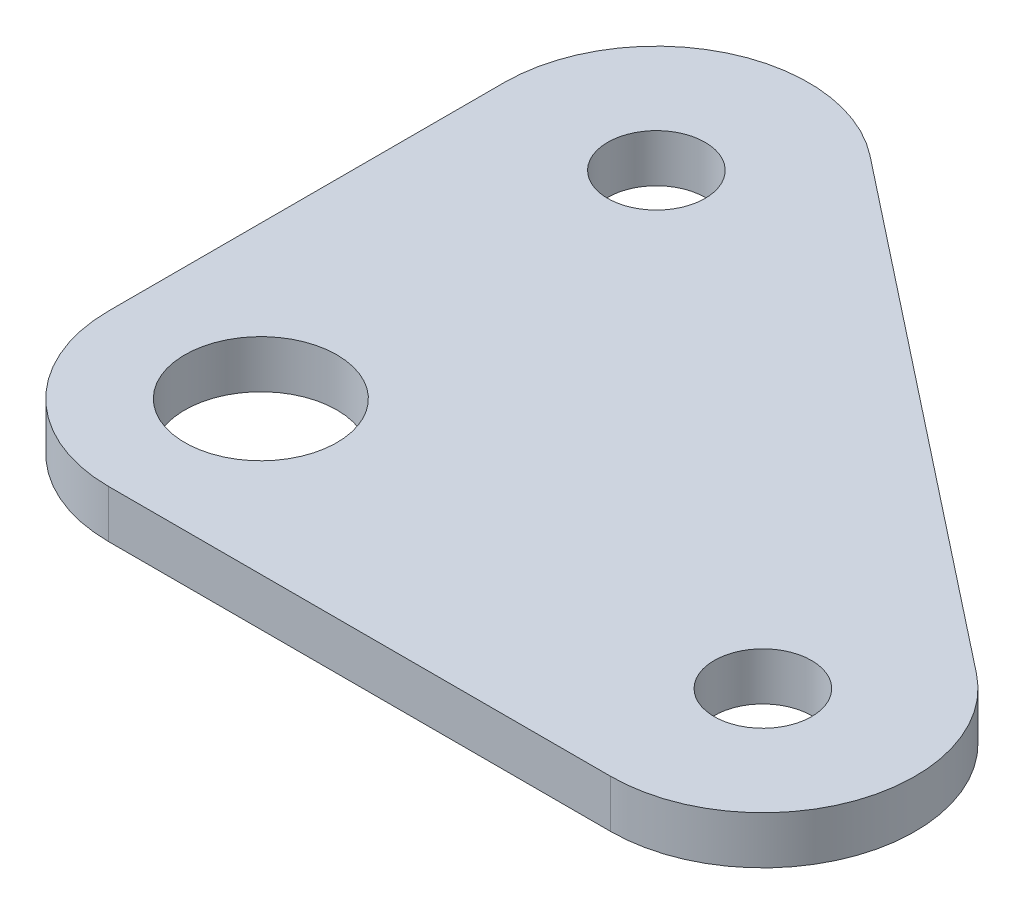
from build123d import *

# Parameters (mm, degrees)
SKETCH1_R           = 1.6
SKETCH1_R_2         = 2.5
BOSS_EXTRUDE1_DEPTH = 1.57


with BuildPart() as part:
    # Sketch1 → Boss-Extrude1 (new body)
    with BuildSketch(Plane(origin=(0, 1.57, 0), x_dir=(1, 0, 0), z_dir=(0, 1, 0))):
        with BuildLine():
            Line((0, -5), (16.5, -5))
            ThreePointArc((16.5, -5), (21.224261413, -1.637484075), (19.594361133, 3.927458361))
            Line((19.594361133, 3.927458361), (3.094361133, 16.927458361))
            ThreePointArc((3.094361133, 16.927458361), (-2.182681188, 17.498433375), (-5, 13))
            Line((-5, 13), (-5, 0))
            ThreePointArc((-5, 0), (-3.535533906, -3.535533906), (0, -5))
        make_face()
        with Locations((0, 13)):
            Circle(SKETCH1_R, mode=Mode.SUBTRACT)
        with Locations((16.5, 0)):
            Circle(SKETCH1_R, mode=Mode.SUBTRACT)
        Circle(SKETCH1_R_2, mode=Mode.SUBTRACT)
    extrude(amount=-BOSS_EXTRUDE1_DEPTH)


solid = part.part
